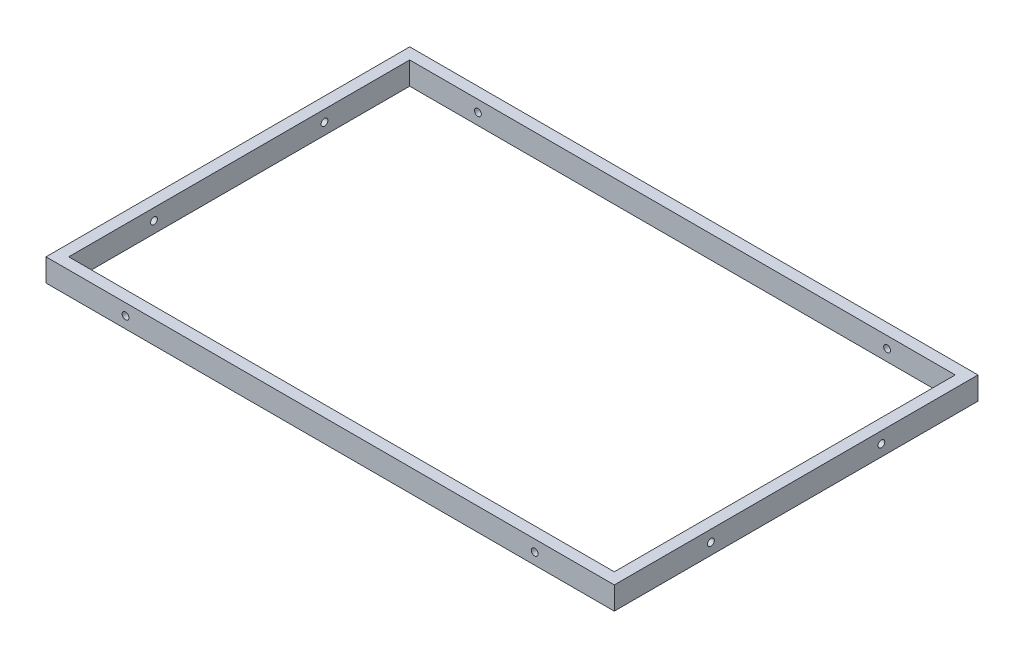
from build123d import *

# Parameters (mm, degrees)
SKETCH1_W           = 500
SKETCH1_H           = 320
SKETCH1_W_2         = 480
SKETCH1_H_2         = 300
BOSS_EXTRUDE1_DEPTH = 20
SKETCH2_R           = 3
CUT_EXTRUDE1_DEPTH  = 500
SKETCH3_R           = 3
CUT_EXTRUDE2_DEPTH  = 320


with BuildPart() as part:
    # Sketch1 → Boss-Extrude1 (new body)
    with BuildSketch(Plane(origin=(0, 0, 0), x_dir=(1, 0, 0), z_dir=(0, 1, 0))):
        Rectangle(SKETCH1_W, SKETCH1_H)
        Rectangle(SKETCH1_W_2, SKETCH1_H_2, mode=Mode.SUBTRACT)
    extrude(amount=BOSS_EXTRUDE1_DEPTH)

    # Sketch2 → Cut-Extrude1 (cut)
    with BuildSketch(Plane(origin=(250, 0, 0), x_dir=(0, 0, -1), z_dir=(1, 0, 0))):
        with Locations((75, 10)):
            Circle(SKETCH2_R)
        with Locations((-75, 10)):
            Circle(SKETCH2_R)
    extrude(amount=-CUT_EXTRUDE1_DEPTH, mode=Mode.SUBTRACT)

    # Sketch3 → Cut-Extrude2 (cut)
    with BuildSketch(Plane.XY.offset(160)):
        with Locations((-180, 10)):
            Circle(SKETCH3_R)
        with Locations((180, 10)):
            Circle(SKETCH3_R)
    extrude(amount=-CUT_EXTRUDE2_DEPTH, mode=Mode.SUBTRACT)


solid = part.part
